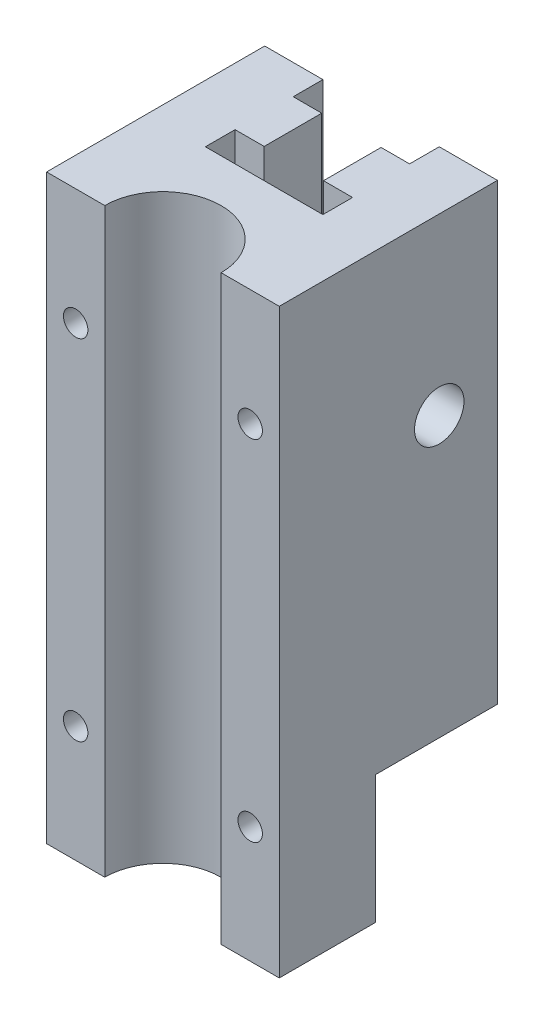
from build123d import *

# Parameters (mm, degrees)
BOSS_EXTRUDE1_DEPTH = 100
SKETCH5_W           = 40
SKETCH5_H           = 21
CUT_EXTRUDE5_DEPTH  = 22
SKETCH3_3_R         = 2.5
CUT_EXTRUDE3_DEPTH  = 115.04494728
SKETCH3_R           = 4.25
SKETCH3_R_2         = 2.5
CUT_EXTRUDE4_DEPTH  = 6
SKETCH7_R           = 2.1
CUT_EXTRUDE7_DEPTH  = 10
CUT_EXTRUDE8_START  = -3
SKETCH10_R          = 2.5
CUT_EXTRUDE8_DEPTH  = 3


with BuildPart() as part:
    # Sketch1 → Boss-Extrude1 (new body)
    with BuildSketch(Plane(origin=(0, 0, 0), x_dir=(1, 0, 0), z_dir=(0, 1, 0))):
        with BuildLine():
            Line((-10, -5.1), (-10, 0))
            Line((-10, 0), (-20, 0))
            Line((-20, 0), (-20, -37.5))
            Line((-20, -37.5), (-10, -37.5))
            ThreePointArc((-10, -37.5), (0, -27.5), (10, -37.5))
            Line((10, -37.5), (20, -37.5))
            Line((20, -37.5), (20, 0))
            Line((20, 0), (10, 0))
            Line((10, 0), (10, -5.1))
            Line((10, -5.1), (5.1, -5.1))
            Line((5.1, -5.1), (5.1, -15))
            Line((5.1, -15), (10.1, -15))
            Line((10.1, -15), (10.1, -20.1))
            Line((10.1, -20.1), (-10.1, -20.1))
            Line((-10.1, -20.1), (-10.1, -15))
            Line((-10.1, -15), (-5.1, -15))
            Line((-5.1, -15), (-5.1, -5.1))
            Line((-5.1, -5.1), (-10, -5.1))
        make_face()
    extrude(amount=-BOSS_EXTRUDE1_DEPTH)

    # Sketch5 → Cut-Extrude5 (cut)
    with BuildSketch(Plane.XZ.offset(100)):
        with Locations((0, 10.5)):
            Rectangle(SKETCH5_W, SKETCH5_H)
    extrude(amount=-CUT_EXTRUDE5_DEPTH, mode=Mode.SUBTRACT)

    # Sketch3_3 → Cut-Extrude3 (cut, through all)
    with BuildSketch(Plane(origin=(20, 0, 0), x_dir=(0, 0, -1), z_dir=(1, 0, 0))):
        with Locations((-10, -30)):
            Circle(SKETCH3_3_R)
    extrude(amount=-CUT_EXTRUDE3_DEPTH, mode=Mode.SUBTRACT)

    # Sketch3 → Cut-Extrude4 (cut)
    with BuildSketch(Plane(origin=(20, 0, 0), x_dir=(0, 0, -1), z_dir=(1, 0, 0))):
        with Locations((-10, -30)):
            Circle(SKETCH3_R)
        with Locations((-10, -30)):
            Circle(SKETCH3_R_2, mode=Mode.SUBTRACT)
    extrude(amount=-CUT_EXTRUDE4_DEPTH, mode=Mode.SUBTRACT)

    # Sketch7 → Cut-Extrude7 (cut)
    with BuildSketch(Plane.XY.offset(37.5)):
        with Locations((-15, -80)):
            Circle(SKETCH7_R)
        with Locations((15, -80)):
            Circle(SKETCH7_R)
        with Locations((-15, -20)):
            Circle(SKETCH7_R)
        with Locations((15, -20)):
            Circle(SKETCH7_R)
    extrude(amount=-CUT_EXTRUDE7_DEPTH, mode=Mode.SUBTRACT)

    # Sketch10 → Cut-Extrude8 (cut)
    with BuildSketch(Plane.ZY.offset(20).offset(CUT_EXTRUDE8_START)):
        Polygon((13.49946403, -29.9387505), (11.696688392, -26.9387505), (8.197224362, -27), (6.50053597, -30.0612495), (8.303311608, -33.0612495), (11.802775638, -33), align=None)
        with Locations((10, -30)):
            Circle(SKETCH10_R, mode=Mode.SUBTRACT)
    extrude(amount=CUT_EXTRUDE8_DEPTH, mode=Mode.SUBTRACT)


solid = part.part
